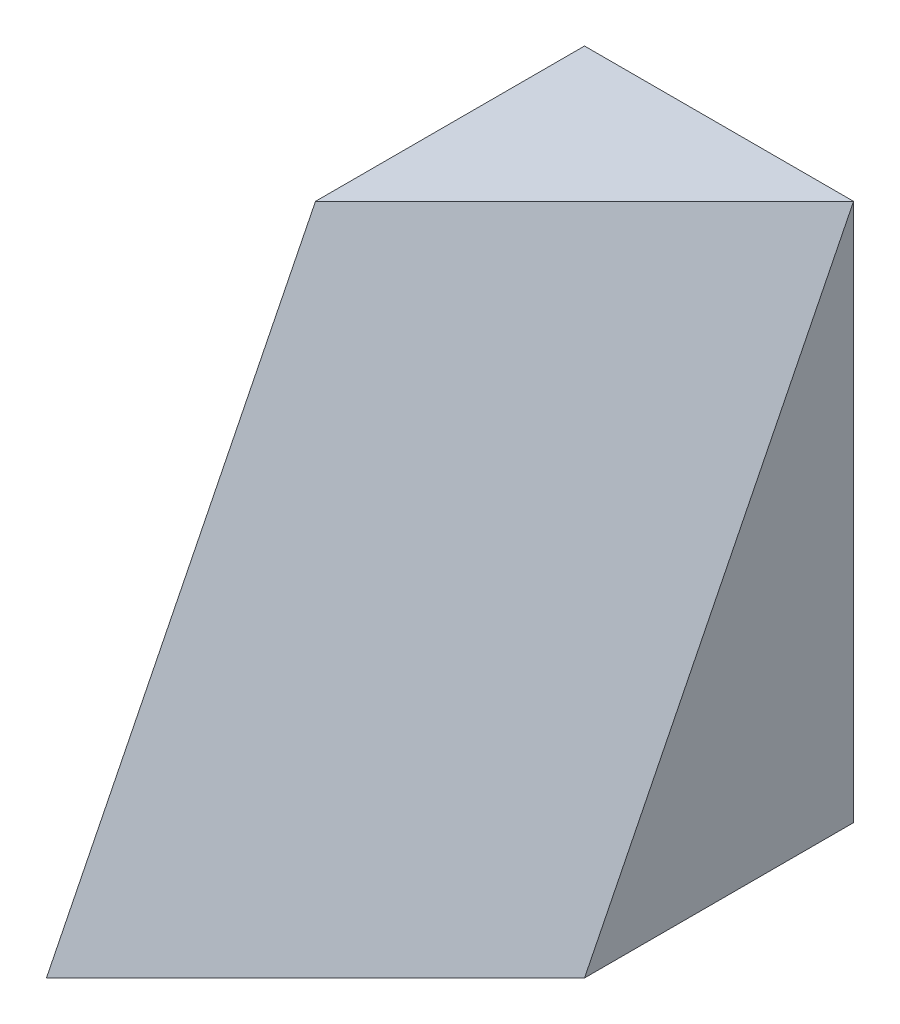
from build123d import *

# Parameters (mm, degrees)
SKETCH1_W           = 40
SKETCH1_H           = 40
BOSS_EXTRUDE1_DEPTH = 40
CUT_EXTRUDE1_DEPTH  = 40
CUT_EXTRUDE2_DEPTH  = 40
CUT_EXTRUDE10_DEPTH = 40
CUT_EXTRUDE11_DEPTH = 40
CUT_EXTRUDE12_DEPTH = 40


with BuildPart() as part:
    # Sketch1 → Boss-Extrude1 (new body)
    with BuildSketch(Plane.XY):
        with Locations((20, 20)):
            Rectangle(SKETCH1_W, SKETCH1_H)
    extrude(amount=BOSS_EXTRUDE1_DEPTH)

    # Sketch2 → Cut-Extrude1 (cut)
    with BuildSketch(Plane.XY.offset(40)):
        Polygon((0, 0), (20, 40), (0, 40), align=None)
    extrude(amount=-CUT_EXTRUDE1_DEPTH, mode=Mode.SUBTRACT)

    # Sketch3 → Cut-Extrude2 (cut)
    with BuildSketch(Plane(origin=(0, 0, 0), x_dir=(-1, 0, 0), z_dir=(0, -1, 0))):
        Polygon((0, 0), (-20, -20), (-20, -40), (0, -40), align=None)
    extrude(amount=-CUT_EXTRUDE2_DEPTH, mode=Mode.SUBTRACT)

    # Sketch12 → Cut-Extrude10 (cut)
    with BuildSketch(Plane.ZY.offset(-20)):
        Polygon((20, 40), (40, 0), (40, 40), align=None)
    extrude(amount=-CUT_EXTRUDE10_DEPTH, mode=Mode.SUBTRACT)

    # Sketch13 → Cut-Extrude11 (cut)
    with BuildSketch(Plane.XZ):
        Polygon((20, 40), (40, 20), (40, 40), align=None)
    extrude(amount=-CUT_EXTRUDE11_DEPTH, mode=Mode.SUBTRACT)

    # Sketch14 → Cut-Extrude12 (cut)
    with BuildSketch(Plane(origin=(26.666666667, 13.333333333, 26.666666667), x_dir=(-0.745355992, 0.298142397, 0.596284794), z_dir=(-0.666666667, -0.333333333, -0.666666667))):
        Polygon((-17.88854382, 35.77708764), (-17.88854382, -8.94427191), (8.94427191, -17.88854382), (8.94427191, 26.83281573), align=None)
    extrude(amount=-CUT_EXTRUDE12_DEPTH, mode=Mode.SUBTRACT)


solid = part.part
